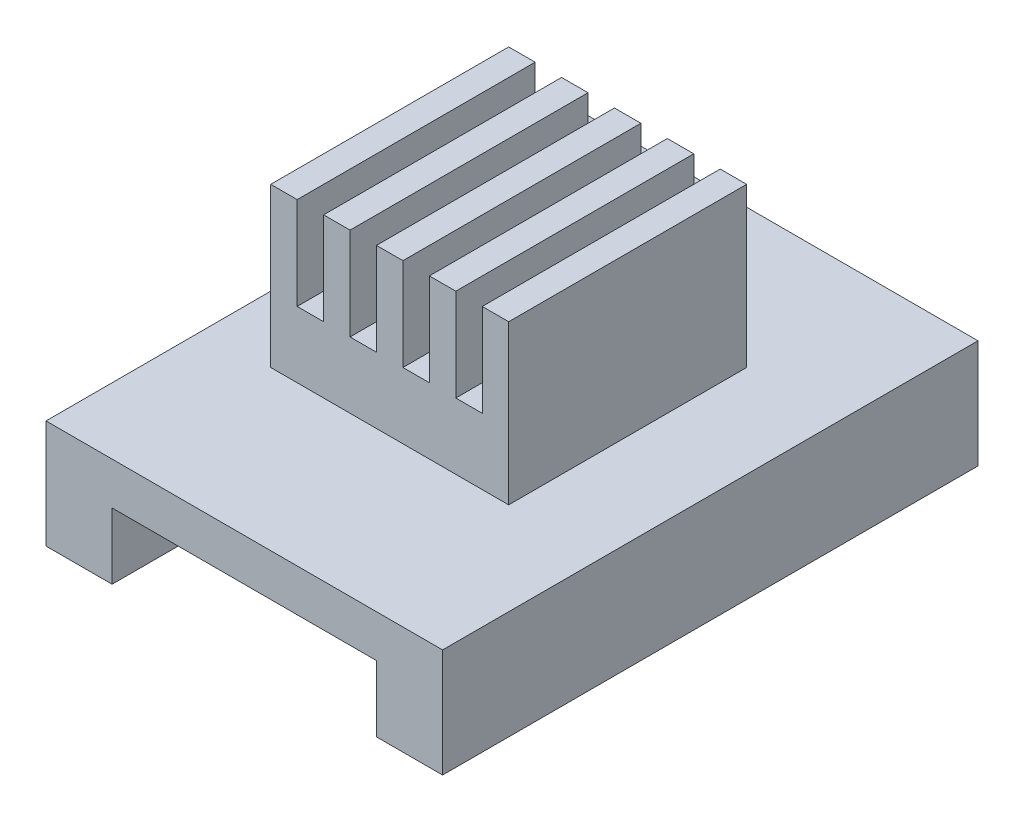
from build123d import *

# Parameters (mm, degrees)
SKETCH1_W           = 15
SKETCH1_H           = 20.25
BOSS_EXTRUDE1_DEPTH = 1.6
SKETCH2_W           = 2.5
SKETCH2_H           = 20.25
BOSS_EXTRUDE2_DEPTH = 2.5
SKETCH3_W           = 9
SKETCH3_H           = 9
BOSS_EXTRUDE3_DEPTH = 6
CUT_EXTRUDE1_REACH  = 16.25
SKETCH4_W           = 1
SKETCH4_H           = 3.5


with BuildPart() as part:
    # Sketch1 → Boss-Extrude1 (new body)
    with BuildSketch(Plane(origin=(0, 0, 0), x_dir=(1, 0, 0), z_dir=(0, 1, 0))):
        with Locations((7.5, 10.125)):
            Rectangle(SKETCH1_W, SKETCH1_H)
    extrude(amount=BOSS_EXTRUDE1_DEPTH)

    # Sketch2 → Boss-Extrude2 (add)
    with BuildSketch(Plane.XZ):
        with Locations((1.25, -10.125)):
            Rectangle(SKETCH2_W, SKETCH2_H)
        with Locations((13.75, -10.125)):
            Rectangle(SKETCH2_W, SKETCH2_H)
    extrude(amount=BOSS_EXTRUDE2_DEPTH)

    # Sketch3 → Boss-Extrude3 (add)
    with BuildSketch(Plane(origin=(0, 1.6, 0), x_dir=(1, 0, 0), z_dir=(0, 1, 0))):
        with Locations((7, 10.5)):
            Rectangle(SKETCH3_W, SKETCH3_H)
    extrude(amount=BOSS_EXTRUDE3_DEPTH)

    # Sketch4 → Cut-Extrude1 (cut, up to next)
    with BuildSketch(Plane.XY.offset(-6), mode=Mode.PRIVATE) as cut_extrude1_sk1:
        with Locations((4, 5.85)):
            Rectangle(SKETCH4_W, SKETCH4_H)
    cut_extrude1_tool1 = extrude(cut_extrude1_sk1.sketch, amount=-CUT_EXTRUDE1_REACH, mode=Mode.PRIVATE) & part.part
    add(cut_extrude1_tool1.solids().sort_by_distance((4, 5.85, -6))[0], mode=Mode.SUBTRACT)
    # Sketch4 → Cut-Extrude1 (cut, up to next)
    with BuildSketch(Plane.XY.offset(-6), mode=Mode.PRIVATE) as cut_extrude1_sk2:
        with Locations((6, 5.85)):
            Rectangle(SKETCH4_W, SKETCH4_H)
    cut_extrude1_tool2 = extrude(cut_extrude1_sk2.sketch, amount=-CUT_EXTRUDE1_REACH, mode=Mode.PRIVATE) & part.part
    add(cut_extrude1_tool2.solids().sort_by_distance((6, 5.85, -6))[0], mode=Mode.SUBTRACT)
    # Sketch4 → Cut-Extrude1 (cut, up to next)
    with BuildSketch(Plane.XY.offset(-6), mode=Mode.PRIVATE) as cut_extrude1_sk3:
        with Locations((8, 5.85)):
            Rectangle(SKETCH4_W, SKETCH4_H)
    cut_extrude1_tool3 = extrude(cut_extrude1_sk3.sketch, amount=-CUT_EXTRUDE1_REACH, mode=Mode.PRIVATE) & part.part
    add(cut_extrude1_tool3.solids().sort_by_distance((8, 5.85, -6))[0], mode=Mode.SUBTRACT)
    # Sketch4 → Cut-Extrude1 (cut, up to next)
    with BuildSketch(Plane.XY.offset(-6), mode=Mode.PRIVATE) as cut_extrude1_sk4:
        with Locations((10, 5.85)):
            Rectangle(SKETCH4_W, SKETCH4_H)
    cut_extrude1_tool4 = extrude(cut_extrude1_sk4.sketch, amount=-CUT_EXTRUDE1_REACH, mode=Mode.PRIVATE) & part.part
    add(cut_extrude1_tool4.solids().sort_by_distance((10, 5.85, -6))[0], mode=Mode.SUBTRACT)


solid = part.part
